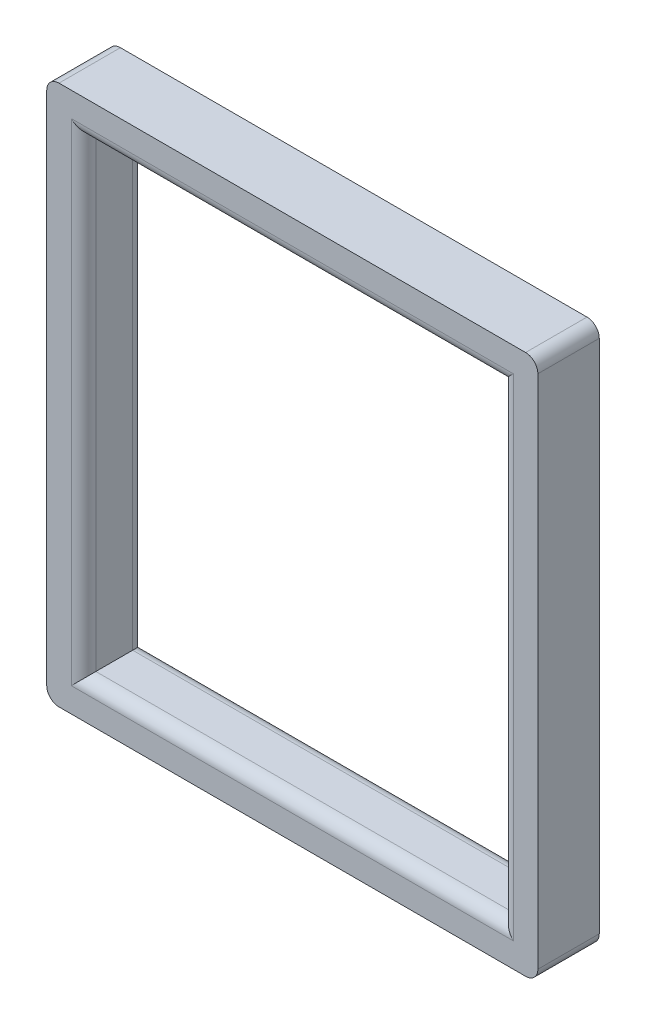
from build123d import *

# Parameters (mm, degrees)
SKETCH1_W           = 25.4
SKETCH1_H           = 27.94
SKETCH1_W_2         = 21.59
SKETCH1_H_2         = 24.13
BOSS_EXTRUDE1_DEPTH = 3.175
FILLET1_R           = 0.635


with BuildPart() as part:
    # Sketch1 → Boss-Extrude1 (new body)
    with BuildSketch(Plane.XY):
        Rectangle(SKETCH1_W, SKETCH1_H)
        Rectangle(SKETCH1_W_2, SKETCH1_H_2, mode=Mode.SUBTRACT)
    extrude(amount=BOSS_EXTRUDE1_DEPTH)

    # Fillet1
    fillet1_edges = [part.edges().sort_by_distance(p)[0] for p in [
        (10.795, 0, 0),
        (0, 12.065, 0),
        (-10.795, 0, 0),
        (0, -12.065, 0),
        (10.795, 0, 3.175),
        (0, 12.065, 3.175),
        (-10.795, 0, 3.175),
        (0, -12.065, 3.175),
        (12.7, -13.97, 1.5875),
        (-12.7, -13.97, 1.5875),
        (-12.7, 13.97, 1.5875),
        (12.7, 13.97, 1.5875),
    ]]
    fillet(fillet1_edges, radius=FILLET1_R)


solid = part.part
